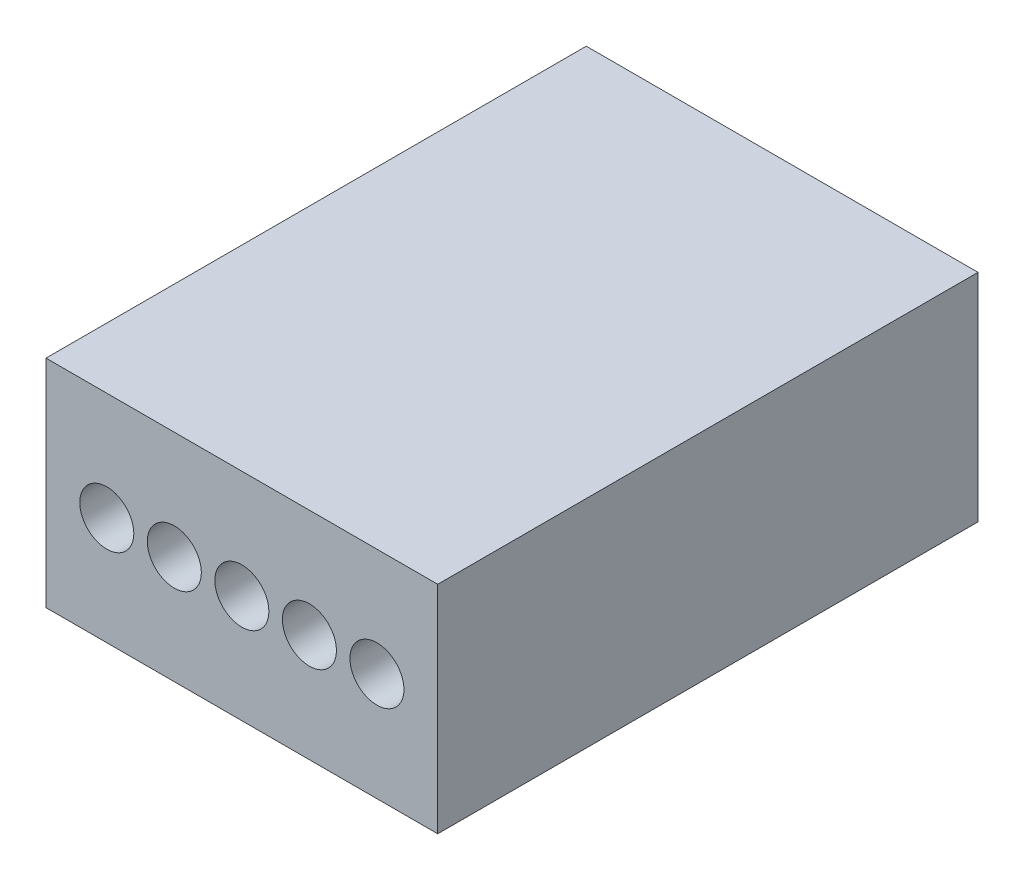
from build123d import *

# Parameters (mm, degrees)
SKETCH2_W           = 7.25
SKETCH2_H           = 4
BOSS_EXTRUDE1_DEPTH = 10
SKETCH3_R           = 0.5
CUT_EXTRUDE1_DEPTH  = 5


with BuildPart() as part:
    # Sketch2 → Boss-Extrude1 (new body)
    with BuildSketch(Plane.XY):
        with Locations((3.625, 2)):
            Rectangle(SKETCH2_W, SKETCH2_H)
    extrude(amount=BOSS_EXTRUDE1_DEPTH)

    # Sketch3 → Cut-Extrude1 (cut)
    with BuildSketch(Plane.XY.offset(10)):
        with Locations((1.125, 2)):
            Circle(SKETCH3_R)
        with Locations((2.375, 2)):
            Circle(SKETCH3_R)
        with Locations((3.625, 2)):
            Circle(SKETCH3_R)
        with Locations((4.875, 2)):
            Circle(SKETCH3_R)
        with Locations((6.125, 2)):
            Circle(SKETCH3_R)
    extrude(amount=-CUT_EXTRUDE1_DEPTH, mode=Mode.SUBTRACT)


solid = part.part
